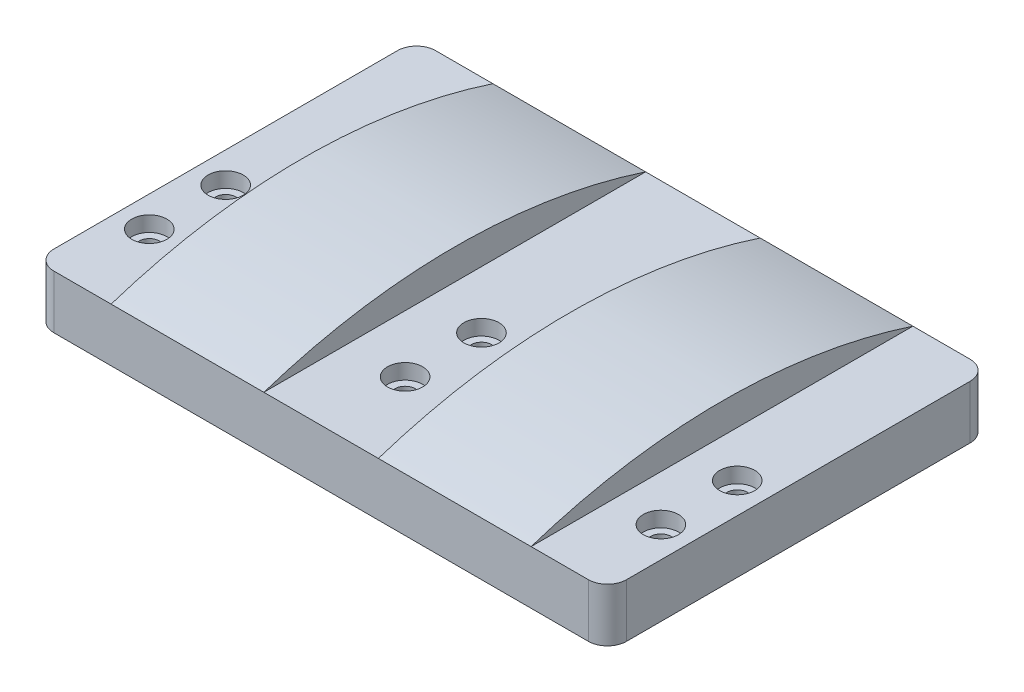
from build123d import *

# Parameters (mm, degrees)
SKETCH1_W           = 150
SKETCH1_H           = 100
BOSS_EXTRUDE1_DEPTH = 14
SKETCH2_R           = 2.65
CUT_EXTRUDE1_DEPTH  = 15
SKETCH4_R           = 4.6
CUT_EXTRUDE2_DEPTH  = 4
BOSS_EXTRUDE3_START = 15
BOSS_EXTRUDE3_DEPTH = 40
FILLET1_R           = 5


with BuildPart() as part:
    # Sketch1 → Boss-Extrude1 (new body)
    with BuildSketch(Plane(origin=(0, 0, 0), x_dir=(1, 0, 0), z_dir=(0, 1, 0))):
        with Locations((75, 50)):
            Rectangle(SKETCH1_W, SKETCH1_H)
    extrude(amount=BOSS_EXTRUDE1_DEPTH)

    # Sketch2 → Cut-Extrude1 (cut, through all)
    with BuildSketch(Plane(origin=(0, 14, 0), x_dir=(1, 0, 0), z_dir=(0, 1, 0))):
        with Locations((8, 42)):
            Circle(SKETCH2_R)
        with Locations((142, 42)):
            Circle(SKETCH2_R)
        with Locations((75, 42)):
            Circle(SKETCH2_R)
        with Locations((142, 22)):
            Circle(SKETCH2_R)
        with Locations((75, 22)):
            Circle(SKETCH2_R)
        with Locations((8, 22)):
            Circle(SKETCH2_R)
    extrude(amount=-CUT_EXTRUDE1_DEPTH, mode=Mode.SUBTRACT)

    # Sketch4 → Cut-Extrude2 (cut)
    with BuildSketch(Plane(origin=(0, 14, 0), x_dir=(1, 0, 0), z_dir=(0, 1, 0))):
        with Locations((8, 42)):
            Circle(SKETCH4_R)
        with Locations((75, 42)):
            Circle(SKETCH4_R)
        with Locations((142, 42)):
            Circle(SKETCH4_R)
        with Locations((8, 22)):
            Circle(SKETCH4_R)
        with Locations((75, 22)):
            Circle(SKETCH4_R)
        with Locations((142, 22)):
            Circle(SKETCH4_R)
    extrude(amount=-CUT_EXTRUDE2_DEPTH, mode=Mode.SUBTRACT)

    # Sketch6 → Boss-Extrude3 (add)
    with BuildSketch(Plane(origin=(75, 0, 0), x_dir=(0, 0, -1), z_dir=(1, 0, 0)).offset(BOSS_EXTRUDE3_START)):
        with BuildLine():
            Line((0, 14), (100, 14))
            ThreePointArc((100, 14), (50, 22), (0, 14))
        make_face()
    boss_extrude3 = extrude(amount=BOSS_EXTRUDE3_DEPTH)

    # Mirror1: Boss-Extrude3 across plane
    add(boss_extrude3.mirror(Plane(origin=(75, 0, 0), x_dir=(0, 0, 1), z_dir=(1, 0, 0))))

    # Fillet1
    fillet1_edges = [part.edges().sort_by_distance(p)[0] for p in [
        (0, 7, -100),
        (150, 7, -100),
        (150, 7, 0),
        (0, 7, 0),
    ]]
    fillet(fillet1_edges, radius=FILLET1_R)


solid = part.part
